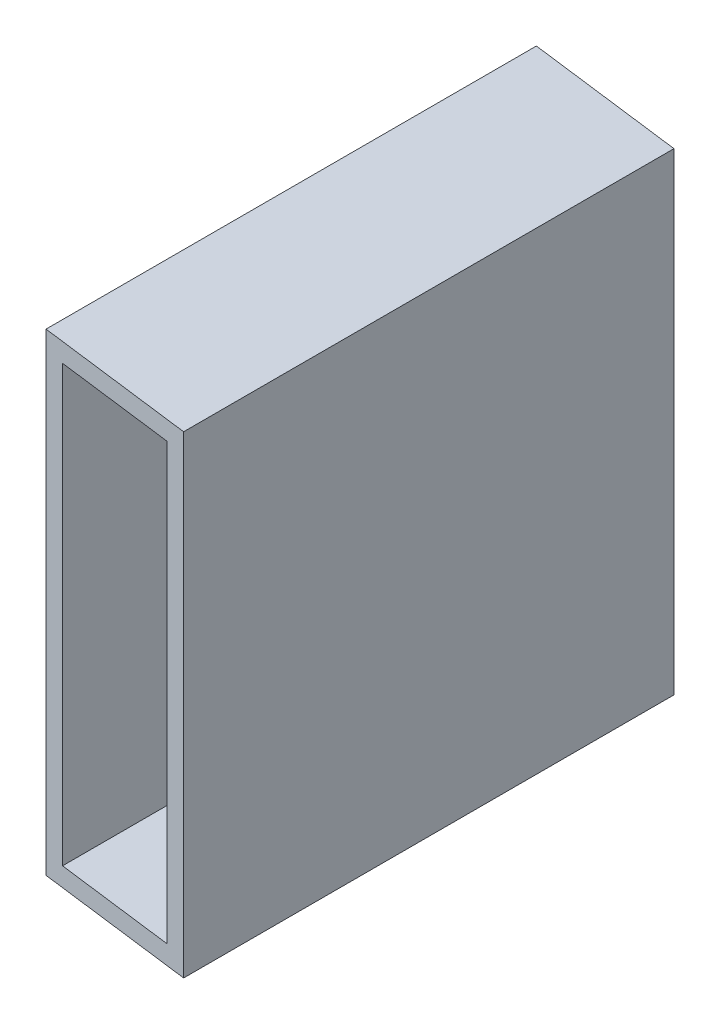
from build123d import *

# Parameters (mm, degrees)
SKETCH2_W               = 9.652
SKETCH2_H               = 3.048
SKETCH2_W_2             = 3.048
SKETCH2_H_2             = 35.052
BOSS_EXTRUDE1_DEPTH     = 78.985121
SKETCH5_W               = 25.4
SKETCH5_H               = 76.2
SKETCH5_W_2             = 19.304
SKETCH5_H_2             = 70.104
BOSS_EXTRUDE3_DEPTH     = 50
CUT_EXTRUDE1_DEPTH      = 1
CUT_EXTRUDE1_DEPTH_BACK = 77.2
SKETCH7_W               = 25.4
SKETCH7_H               = 76.2
SKETCH7_W_2             = 19.304
SKETCH7_H_2             = 70.104
BOSS_EXTRUDE4_DEPTH     = 50
CUT_EXTRUDE2_DEPTH      = 1
CUT_EXTRUDE2_DEPTH_BACK = 77.2


with BuildPart() as part:
    # Sketch2 → Boss-Extrude1 (new body)
    with BuildSketch(Plane.XY):
        Polygon((-12.7, 0), (-9.652, 0), (-9.652, 35.052), (-9.652, 38.1), (-12.7, 38.1), align=None)
        with Locations((-4.826, 36.576)):
            Rectangle(SKETCH2_W, SKETCH2_H)
        Polygon((0, 38.1), (0, 35.052), (9.652, 35.052), (9.652, 0), (12.7, 0), (12.7, 38.1), align=None)
        with Locations((11.176, -17.526)):
            Rectangle(SKETCH2_W_2, SKETCH2_H_2)
        Polygon((-9.652, -35.052), (-9.652, 0), (-12.7, 0), (-12.7, -38.1), (0, -38.1), (0, -35.052), align=None)
        Polygon((9.652, -35.052), (0, -35.052), (0, -38.1), (12.7, -38.1), (12.7, -35.052), align=None)
    extrude(amount=BOSS_EXTRUDE1_DEPTH)

    # Sketch5 → Boss-Extrude3 (add)
    with BuildSketch(Plane(origin=(0, 0, 0), x_dir=(-1, 0, 0), z_dir=(0, 0, -1))):
        Rectangle(SKETCH5_W, SKETCH5_H)
        Rectangle(SKETCH5_W_2, SKETCH5_H_2, mode=Mode.SUBTRACT)
    extrude(amount=BOSS_EXTRUDE3_DEPTH)

    # Sketch6 → Cut-Extrude1 (cut, two sides)
    with BuildSketch(Plane.XZ.offset(38.1)) as cut_extrude1_sk:
        Polygon((-12.7, -1.617644511), (-45.228253893, -5.760884774), (-37.756637, -64.41996217), (45.640291612, -53.797396519), (38.168674718, 4.861680877), (12.7, -48.058587426), (12.7, -50), (-12.7, -50), align=None)
        Polygon((0, 0), (-12.7, -1.617644511), (-12.7, -50), (12.7, -50), (12.7, -48.058587426), (12.534006261, -48.403498707), align=None)
        Polygon((38.168674718, 4.861680877), (12.7, 1.617644511), (12.7, -48.058587426), align=None)
        Polygon((12.7, 1.617644511), (0, 0), (12.534006261, -48.403498707), (12.7, -48.058587426), align=None)
    extrude(amount=CUT_EXTRUDE1_DEPTH, mode=Mode.SUBTRACT)
    extrude(cut_extrude1_sk.sketch, amount=-CUT_EXTRUDE1_DEPTH_BACK, mode=Mode.SUBTRACT)

    # Sketch7 → Boss-Extrude4 (add)
    with BuildSketch(Plane.XY.offset(78.985120912)):
        Rectangle(SKETCH7_W, SKETCH7_H)
        Rectangle(SKETCH7_W_2, SKETCH7_H_2, mode=Mode.SUBTRACT)
    extrude(amount=BOSS_EXTRUDE4_DEPTH)

    # Sketch8 → Cut-Extrude2 (cut, two sides)
    with BuildSketch(Plane(origin=(0, 38.1, 0), x_dir=(1, 0, 0), z_dir=(0, 1, 0))) as cut_extrude2_sk:
        Polygon((-12.534006261, -127.388619619), (-12.7, -126.667826545), (-12.7, -128.985120912), (12.7, -128.985120912), (12.7, -80.602765422), (0, -78.985120912), align=None)
        Polygon((-12.7, -77.367476401), (-24.396635689, -75.877633998), (-12.7, -126.667826545), align=None)
        Polygon((0, -78.985120912), (-12.7, -77.367476401), (-12.7, -126.667826545), (-12.534006261, -127.388619619), align=None)
    extrude(amount=CUT_EXTRUDE2_DEPTH, mode=Mode.SUBTRACT)
    extrude(cut_extrude2_sk.sketch, amount=-CUT_EXTRUDE2_DEPTH_BACK, mode=Mode.SUBTRACT)


solid = part.part
